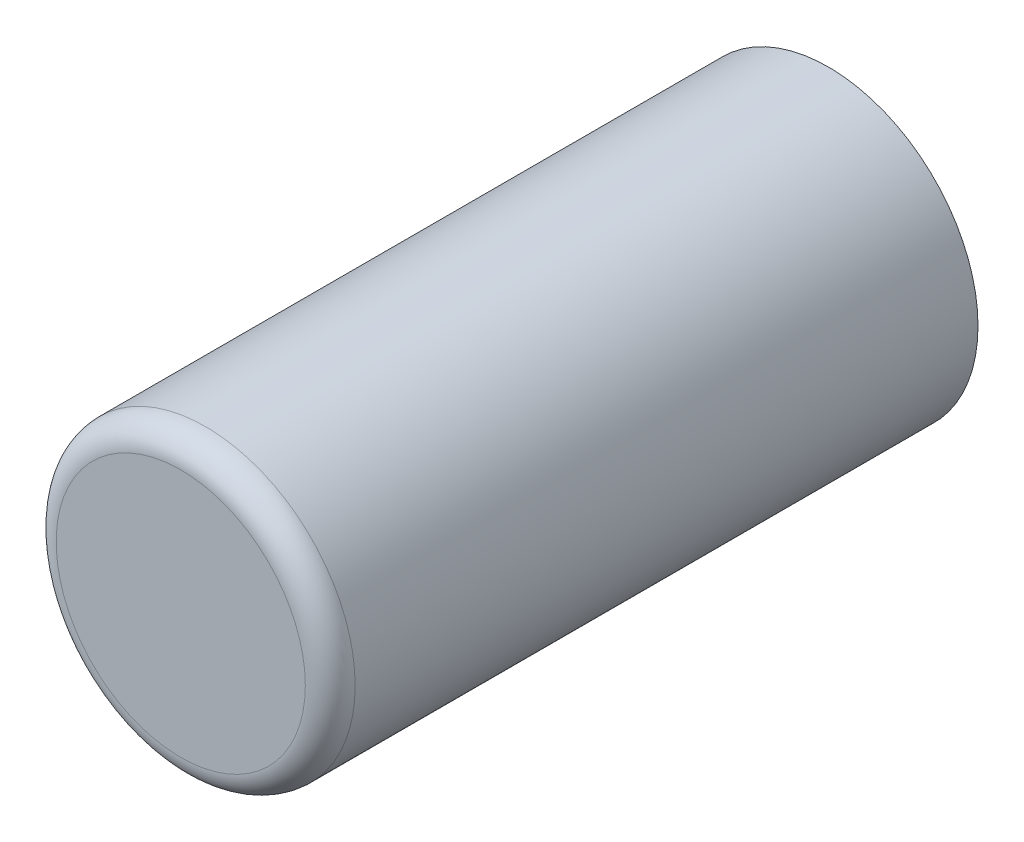
from build123d import *

# Parameters (mm, degrees)
SKETCH1_R           = 4.8
BOSS_EXTRUDE1_DEPTH = 10.4
FILLET1_R           = 0.8


with BuildPart() as part:
    # Sketch1 → Boss-Extrude1 (new body, symmetric)
    with BuildSketch(Plane.XY):
        Circle(SKETCH1_R)
    extrude(amount=BOSS_EXTRUDE1_DEPTH, both=True)

    # Fillet1
    fillet1_edges = [part.edges().sort_by_distance(p)[0] for p in [
        (-4.8, 0, 10.4),
    ]]
    fillet(fillet1_edges, radius=FILLET1_R)


solid = part.part
